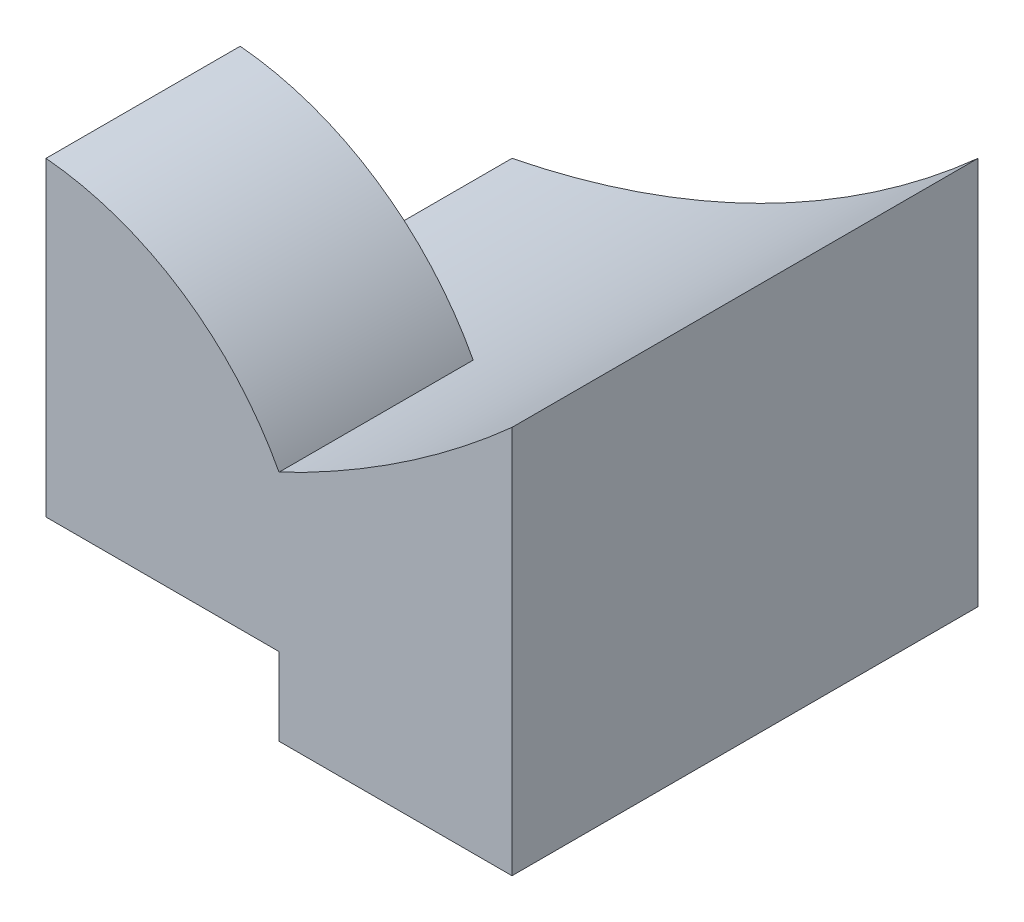
from build123d import *

# Parameters (mm, degrees)
SKETCH1_W           = 6
SKETCH1_H           = 6
BOSS_EXTRUDE1_DEPTH = 5
CUT_EXTRUDE7_DEPTH  = 12.5
CUT_EXTRUDE8_DEPTH  = 3.5
SKETCH10_W          = 3
SKETCH10_H          = 1
CUT_EXTRUDE9_DEPTH  = 2.5


with BuildPart() as part:
    # Sketch1 → Boss-Extrude1 (new body)
    with BuildSketch(Plane(origin=(0, 0, 0), x_dir=(1, 0, 0), z_dir=(0, 1, 0))):
        Rectangle(SKETCH1_W, SKETCH1_H)
    extrude(amount=BOSS_EXTRUDE1_DEPTH)

    # Sketch8 → Cut-Extrude7 (cut)
    with BuildSketch(Plane.XY.offset(3)):
        with BuildLine():
            ThreePointArc((0, 3), (1.571067812, 3.893398282), (3, 5))
            Line((3, 5), (-3, 5))
            ThreePointArc((-3, 5), (-1.245414444, 4.381878334), (0, 3))
        make_face()
    extrude(amount=-CUT_EXTRUDE7_DEPTH, mode=Mode.SUBTRACT)

    # Sketch9 → Cut-Extrude8 (cut)
    with BuildSketch(Plane(origin=(0, 0, -3), x_dir=(-1, 0, 0), z_dir=(0, 0, -1))):
        with BuildLine():
            ThreePointArc((0, 3), (1.468871126, 2.406613378), (3, 2))
            Line((3, 2), (3, 5))
            ThreePointArc((3, 5), (1.245414444, 4.381878334), (0, 3))
        make_face()
    extrude(amount=-CUT_EXTRUDE8_DEPTH, mode=Mode.SUBTRACT)

    # Sketch10 → Cut-Extrude9 (cut)
    with BuildSketch(Plane.XY.offset(3)):
        with Locations((-1.5, 0.5)):
            Rectangle(SKETCH10_W, SKETCH10_H)
    extrude(amount=-CUT_EXTRUDE9_DEPTH, mode=Mode.SUBTRACT)


solid = part.part
